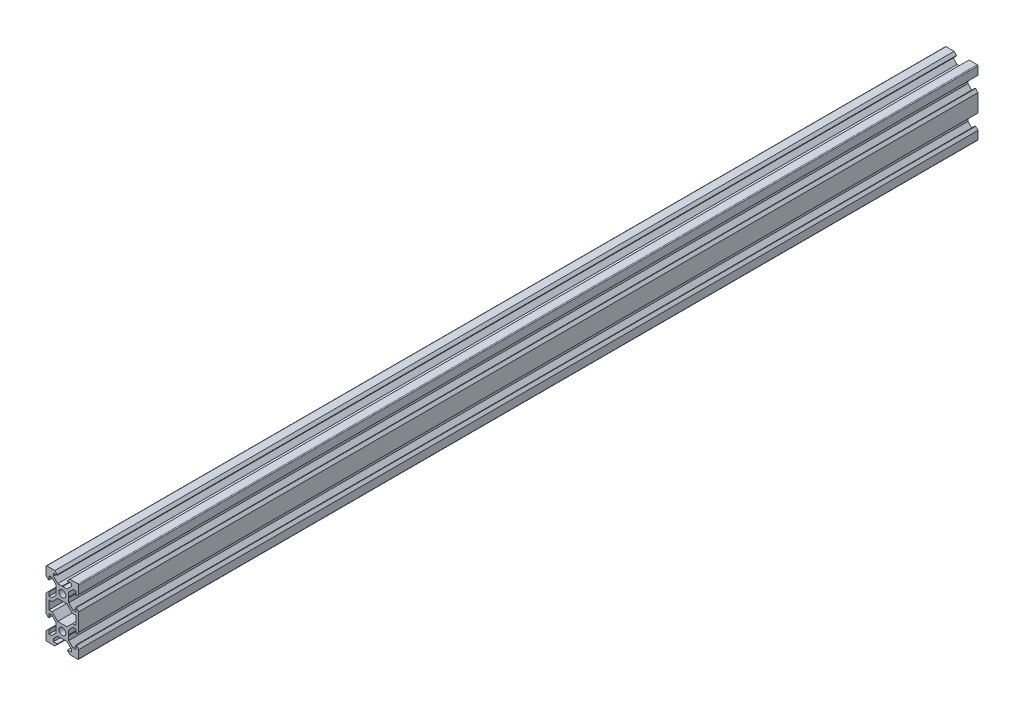
from build123d import *

# Parameters (mm, degrees)
SKETCH1_R           = 2.1
BOSS_EXTRUDE1_DEPTH = 550


with BuildPart() as part:
    # Sketch1 → Boss-Extrude1 (new body)
    with BuildSketch(Plane.XY):
        with BuildLine():
            Line((4.58, -20), (9.5, -20))
            ThreePointArc((9.5, -20), (9.853553391, -19.853553391), (10, -19.5))
            Line((10, -19.5), (10, -14.58))
            Line((10, -14.58), (8.545, -13.125))
            Line((8.545, -13.125), (8.2, -13.125))
            Line((8.2, -13.125), (8.2, -15.5))
            Line((8.2, -15.5), (6.560660172, -15.5))
            Line((6.560660172, -15.5), (3.9, -12.839339828))
            Line((3.9, -12.839339828), (3.9, -10.21))
            Line((3.9, -10.21), (3.69, -10))
            Line((3.69, -10), (3.9, -9.79))
            Line((3.9, -9.79), (3.9, -7.160660172))
            Line((3.9, -7.160660172), (6.560660172, -4.5))
            Line((6.560660172, -4.5), (8.2, -4.5))
            Line((8.2, -4.5), (8.2, -6.875))
            Line((8.2, -6.875), (8.545, -6.875))
            Line((8.545, -6.875), (10, -5.42))
            Line((10, -5.42), (10, 5.42))
            Line((10, 5.42), (8.545, 6.875))
            Line((8.545, 6.875), (8.2, 6.875))
            Line((8.2, 6.875), (8.2, 4.5))
            Line((8.2, 4.5), (6.560660172, 4.5))
            Line((6.560660172, 4.5), (3.9, 7.160660172))
            Line((3.9, 7.160660172), (3.9, 9.79))
            Line((3.9, 9.79), (3.69, 10))
            Line((3.69, 10), (3.9, 10.21))
            Line((3.9, 10.21), (3.9, 12.839339828))
            Line((3.9, 12.839339828), (6.560660172, 15.5))
            Line((6.560660172, 15.5), (8.2, 15.5))
            Line((8.2, 15.5), (8.2, 13.125))
            Line((8.2, 13.125), (8.545, 13.125))
            Line((8.545, 13.125), (10, 14.58))
            Line((10, 14.58), (10, 19.5))
            ThreePointArc((10, 19.5), (9.853553391, 19.853553391), (9.5, 20))
            Line((9.5, 20), (4.58, 20))
            Line((4.58, 20), (3.125, 18.545))
            Line((3.125, 18.545), (3.125, 18.2))
            Line((3.125, 18.2), (5.5, 18.2))
            Line((5.5, 18.2), (5.5, 16.560660172))
            Line((5.5, 16.560660172), (2.839339828, 13.9))
            Line((2.839339828, 13.9), (0.21, 13.9))
            Line((0.21, 13.9), (0, 13.69))
            Line((0, 13.69), (-0.21, 13.9))
            Line((-0.21, 13.9), (-2.839339828, 13.9))
            Line((-2.839339828, 13.9), (-5.5, 16.560660172))
            Line((-5.5, 16.560660172), (-5.5, 18.2))
            Line((-5.5, 18.2), (-3.125, 18.2))
            Line((-3.125, 18.2), (-3.125, 18.545))
            Line((-3.125, 18.545), (-4.58, 20))
            Line((-4.58, 20), (-9.5, 20))
            ThreePointArc((-9.5, 20), (-9.853553391, 19.853553391), (-10, 19.5))
            Line((-10, 19.5), (-10, 14.58))
            Line((-10, 14.58), (-8.545, 13.125))
            Line((-8.545, 13.125), (-8.2, 13.125))
            Line((-8.2, 13.125), (-8.2, 15.5))
            Line((-8.2, 15.5), (-6.560660172, 15.5))
            Line((-6.560660172, 15.5), (-3.9, 12.839339828))
            Line((-3.9, 12.839339828), (-3.9, 10.21))
            Line((-3.9, 10.21), (-3.69, 10))
            Line((-3.69, 10), (-3.9, 9.79))
            Line((-3.9, 9.79), (-3.9, 7.160660172))
            Line((-3.9, 7.160660172), (-6.560660172, 4.5))
            Line((-6.560660172, 4.5), (-8.2, 4.5))
            Line((-8.2, 4.5), (-8.2, 6.875))
            Line((-8.2, 6.875), (-8.545, 6.875))
            Line((-8.545, 6.875), (-10, 5.42))
            Line((-10, 5.42), (-10, -5.42))
            Line((-10, -5.42), (-8.545, -6.875))
            Line((-8.545, -6.875), (-8.2, -6.875))
            Line((-8.2, -6.875), (-8.2, -4.5))
            Line((-8.2, -4.5), (-6.560660172, -4.5))
            Line((-6.560660172, -4.5), (-3.9, -7.160660172))
            Line((-3.9, -7.160660172), (-3.9, -9.79))
            Line((-3.9, -9.79), (-3.69, -10))
            Line((-3.69, -10), (-3.9, -10.21))
            Line((-3.9, -10.21), (-3.9, -12.839339828))
            Line((-3.9, -12.839339828), (-6.560660172, -15.5))
            Line((-6.560660172, -15.5), (-8.2, -15.5))
            Line((-8.2, -15.5), (-8.2, -13.125))
            Line((-8.2, -13.125), (-8.545, -13.125))
            Line((-8.545, -13.125), (-10, -14.58))
            Line((-10, -14.58), (-10, -19.5))
            ThreePointArc((-10, -19.5), (-9.853553391, -19.853553391), (-9.5, -20))
            Line((-9.5, -20), (-4.58, -20))
            Line((-4.58, -20), (-3.125, -18.545))
            Line((-3.125, -18.545), (-3.125, -18.2))
            Line((-3.125, -18.2), (-5.5, -18.2))
            Line((-5.5, -18.2), (-5.5, -16.560660172))
            Line((-5.5, -16.560660172), (-2.839339828, -13.9))
            Line((-2.839339828, -13.9), (-0.21, -13.9))
            Line((-0.21, -13.9), (0, -13.69))
            Line((0, -13.69), (0.21, -13.9))
            Line((0.21, -13.9), (2.839339828, -13.9))
            Line((2.839339828, -13.9), (5.5, -16.560660172))
            Line((5.5, -16.560660172), (5.5, -18.2))
            Line((5.5, -18.2), (3.125, -18.2))
            Line((3.125, -18.2), (3.125, -18.545))
            Line((3.125, -18.545), (4.58, -20))
        make_face()
        with Locations((0, -10)):
            Circle(SKETCH1_R, mode=Mode.SUBTRACT)
        Polygon((-6.239339828, -2.7), (-8.2, -2.7), (-8.2, 2.7), (-6.239339828, 2.7), (-2.839339828, 6.1), (2.839339828, 6.1), (6.239339828, 2.7), (8.2, 2.7), (8.2, -2.7), (6.239339828, -2.7), (2.839339828, -6.1), (-2.839339828, -6.1), align=None, mode=Mode.SUBTRACT)
        with Locations((0, 10)):
            Circle(SKETCH1_R, mode=Mode.SUBTRACT)
    extrude(amount=BOSS_EXTRUDE1_DEPTH)


solid = part.part
